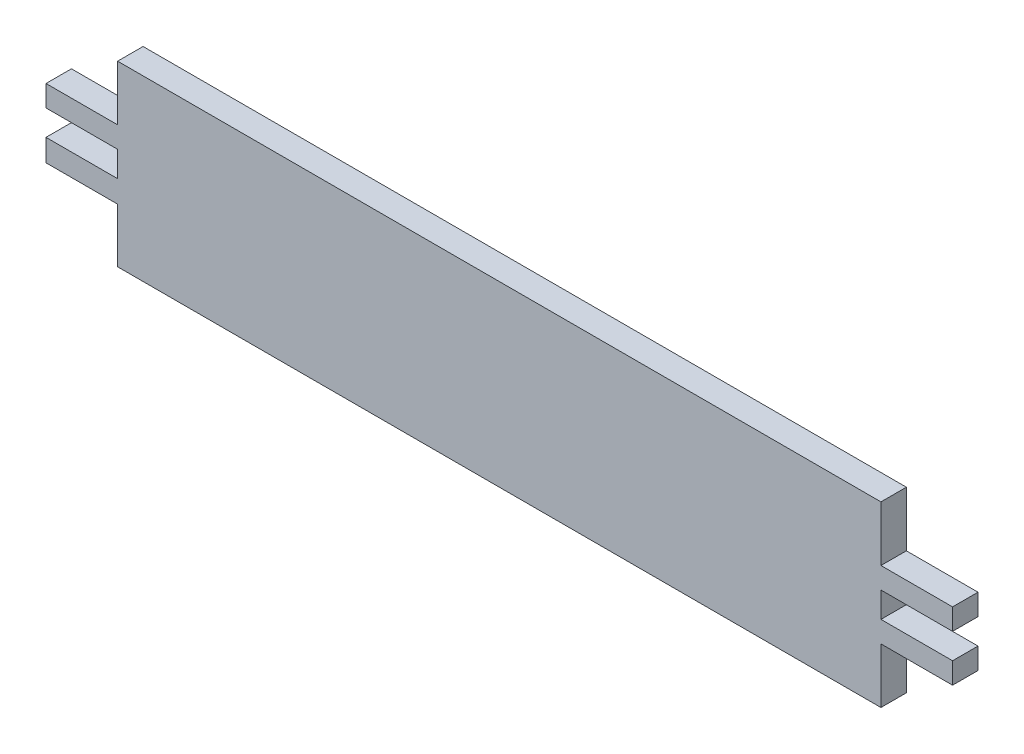
from build123d import *

# Parameters (mm, degrees)
BOSS_EXTRUDE1_DEPTH = 6


with BuildPart() as part:
    # Sketch3 → Boss-Extrude1 (new body)
    with BuildSketch(Plane.XY):
        Polygon((-59.917123056, 29.20445586), (120.082876944, 29.20445586), (120.082876944, 16.20445586), (136.973011288, 16.20445586), (136.973011288, 11.20445586), (120.082876944, 11.20445586), (120.082876944, 5.20445586), (136.973011288, 5.20445586), (136.973011288, 0.20445586), (120.082876944, 0.20445586), (120.082876944, -12.79554414), (-59.917123056, -12.79554414), (-59.917123056, 0), (-76.807123056, 0), (-76.807123056, 5.20445586), (-59.917123056, 5.20445586), (-59.917123056, 11.20445586), (-76.807123056, 11.20445586), (-76.807123056, 16.20445586), (-59.917123056, 16.20445586), align=None)
    extrude(amount=BOSS_EXTRUDE1_DEPTH)


solid = part.part
